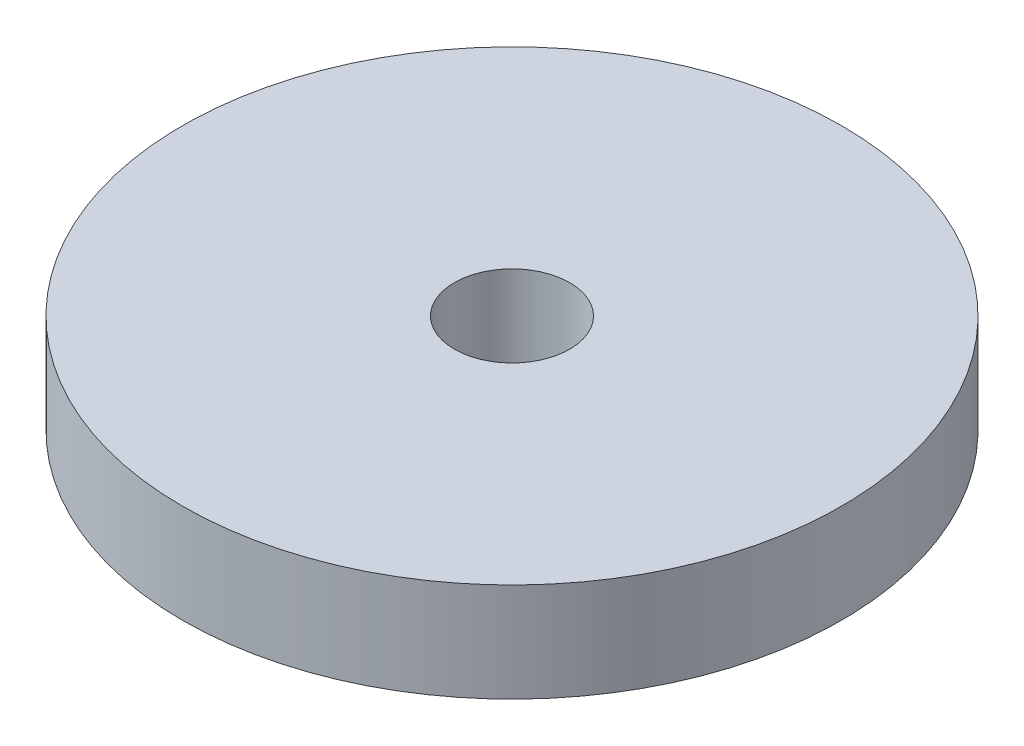
from build123d import *

# Parameters (mm, degrees)
SKETCH1_R           = 20
SKETCH1_R_2         = 3.5
BOSS_EXTRUDE1_DEPTH = 6


with BuildPart() as part:
    # Sketch1 → Boss-Extrude1 (new body)
    with BuildSketch(Plane(origin=(0, 0, 0), x_dir=(1, 0, 0), z_dir=(0, 1, 0))):
        Circle(SKETCH1_R)
        Circle(SKETCH1_R_2, mode=Mode.SUBTRACT)
    extrude(amount=BOSS_EXTRUDE1_DEPTH)


solid = part.part
